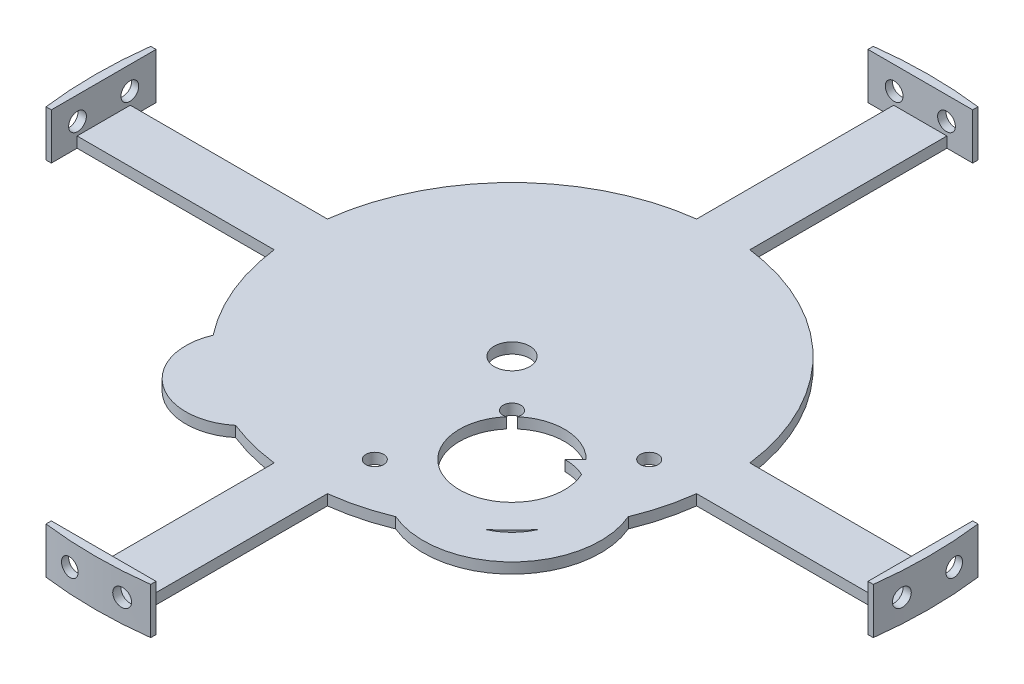
from build123d import *
from build123d.topology import SkipClean

# Parameters (mm, degrees)
SKETCH1_R           = 76.2
BOSS_EXTRUDE1_DEPTH = 3.81
BOSS_EXTRUDE3_DEPTH = 3.81
SKETCH5_R           = 6.35
CUT_EXTRUDE1_DEPTH  = 212.070408513
BOSS_EXTRUDE4_START = -3.81
BOSS_EXTRUDE4_DEPTH = 16.51
SKETCH8_R           = 3.175
CUT_EXTRUDE3_DEPTH  = 332.331209118
CIRPATTERN3_COUNT   = 4
SKETCH9_R           = 3.174999999
CUT_EXTRUDE4_DEPTH  = 3.81
SKETCH11_R          = 31.75
SKETCH11_R_2        = 25.4
BOSS_EXTRUDE5_DEPTH = 3.81
SKETCH12_R          = 25.4
CUT_EXTRUDE5_DEPTH  = 3.81
SKETCH13_R          = 20.52955
SKETCH13_R_2        = 2.3622
BOSS_EXTRUDE7_DEPTH = 3.81
SKETCH14_R          = 2.3622
CUT_EXTRUDE6_DEPTH  = 3.81
SKETCH15_R          = 3.175
CUT_EXTRUDE7_DEPTH  = 3.81
SKETCH16_R          = 25.4
SKETCH16_R_2        = 18.796
BOSS_EXTRUDE8_DEPTH = 3.81
SKETCH17_R          = 3.175
CUT_EXTRUDE8_DEPTH  = 212.417812192
BOSS_EXTRUDE9_START = -3.81
SKETCH19_R          = 3.175
SKETCH19_R_2        = 2.3622
SKETCH19_R_3        = 3.174999999
BOSS_EXTRUDE9_DEPTH = 3.81


with BuildPart() as part:
    # Sketch1 → Boss-Extrude1 (new body)
    with BuildSketch(Plane(origin=(0, 0, 0), x_dir=(1, 0, 0), z_dir=(0, 1, 0))):
        with Locations(Location((0, 0, 0), (0, 0, 90))):
            Circle(SKETCH1_R)
    extrude(amount=BOSS_EXTRUDE1_DEPTH)

    # Sketch3 → Boss-Extrude3 (add)
    with BuildSketch(Plane(origin=(0, 0, 0), x_dir=(-1, 0, 0), z_dir=(0, -1, 0))):
        with BuildLine():
            Line((9.525, -9.525), (148.920700374, -9.525))
            ThreePointArc((148.920700374, -9.525), (149.225, 0), (148.920700374, 9.525))
            Line((148.920700374, 9.525), (9.525, 9.525))
            Line((9.525, 9.525), (9.525, 148.920700374))
            ThreePointArc((9.525, 148.920700374), (0, 149.225), (-9.525, 148.920700374))
            Line((-9.525, 148.920700374), (-9.525, 9.525))
            Line((-9.525, 9.525), (-148.920700374, 9.525))
            ThreePointArc((-148.920700374, 9.525), (-149.225, 0), (-148.920700374, -9.525))
            Line((-148.920700374, -9.525), (-9.525, -9.525))
            Line((-9.525, -9.525), (-9.525, -148.920700374))
            ThreePointArc((-9.525, -148.920700374), (0, -149.225), (9.525, -148.920700374))
            Line((9.525, -148.920700374), (9.525, -9.525))
        make_face()
    extrude(amount=-BOSS_EXTRUDE3_DEPTH)

    # Sketch5 → Cut-Extrude1 (cut, through all)
    with BuildSketch(Plane(origin=(0, 3.81, 0), x_dir=(1, 0, 0), z_dir=(0, 1, 0))):
        with Locations(Location((0, 0, 0), (0, 0, 270))):
            Circle(SKETCH5_R)
    extrude(amount=-CUT_EXTRUDE1_DEPTH, mode=Mode.SUBTRACT)

    # Sketch7 → Boss-Extrude4 (add)
    with BuildSketch(Plane(origin=(0, 3.81, 0), x_dir=(1, 0, 0), z_dir=(0, 1, 0)).offset(BOSS_EXTRUDE4_START)):
        with BuildLine():
            Line((18.739703318, 148.043656212), (18.739703318, 146.138656212))
            Line((18.739703318, 146.138656212), (-18.739703318, 146.138656212))
            Line((-18.739703318, 146.138656212), (-18.739703318, 148.043656212))
            ThreePointArc((-18.739703318, 148.043656212), (0, 149.225), (18.739703318, 148.043656212))
        make_face()
    boss_extrude4 = extrude(amount=BOSS_EXTRUDE4_DEPTH)

    # Sketch8 → Cut-Extrude3 (cut, through all)
    with BuildSketch(Plane.XY.offset(-146.138656212)):
        with Locations((-9.369851659, 8.255)):
            Circle(SKETCH8_R)
        with Locations((9.369851659, 8.255)):
            Circle(SKETCH8_R)
    cut_extrude3 = extrude(amount=-CUT_EXTRUDE3_DEPTH, mode=Mode.SUBTRACT)

    # CirPattern3: Boss-Extrude4, Cut-Extrude3 ×4 about axis
    cirpattern3_axis = Axis((0, 0, 0), (0, 1, 0))
    add([boss_extrude4.rotate(cirpattern3_axis, i * 360 / CIRPATTERN3_COUNT) for i in range(1, CIRPATTERN3_COUNT)])
    add([cut_extrude3.rotate(cirpattern3_axis, i * 360 / CIRPATTERN3_COUNT) for i in range(1, CIRPATTERN3_COUNT)], mode=Mode.SUBTRACT)

    # Sketch9 → Cut-Extrude4 (cut)
    with BuildSketch(Plane.XZ):
        with Locations(Location((-56.514999999, -23.8125, 0), (0, 0, 270))):
            Circle(SKETCH9_R)
        with Locations(Location((-15.874999999, -23.8125, 0), (0, 0, 270))):
            Circle(SKETCH9_R)
    extrude(amount=-CUT_EXTRUDE4_DEPTH, mode=Mode.SUBTRACT)

    # Sketch11 → Boss-Extrude5 (add)
    with BuildSketch(Plane(origin=(0, 3.81, 0), x_dir=(1, 0, 0), z_dir=(0, 1, 0))):
        with Locations((41.275, -41.275)):
            Circle(SKETCH11_R)
        with Locations((41.275, -41.275)):
            Circle(SKETCH11_R_2, mode=Mode.SUBTRACT)
    extrude(amount=-BOSS_EXTRUDE5_DEPTH)

    # Sketch12 → Cut-Extrude5 (cut)
    with BuildSketch(Plane(origin=(0, 3.81, 0), x_dir=(1, 0, 0), z_dir=(0, 1, 0))):
        with Locations(Location((41.275, -41.275, 0), (0, 0, 270))):
            Circle(SKETCH12_R)
    extrude(amount=-CUT_EXTRUDE5_DEPTH, mode=Mode.SUBTRACT)

    # Sketch13 → Boss-Extrude7 (add)
    with BuildSketch(Plane(origin=(0, 3.81, 0), x_dir=(1, 0, 0), z_dir=(0, 1, 0))):
        with Locations((-41.16870274, -55.03340443)):
            Circle(SKETCH13_R)
        with Locations(Location((-41.17109409, -70.730891948, 0), (0, 0, 270))):
            Circle(SKETCH13_R_2, mode=Mode.SUBTRACT)
        with Locations((-41.166311391, -39.335916913)):
            Circle(SKETCH13_R_2, mode=Mode.SUBTRACT)
    extrude(amount=-BOSS_EXTRUDE7_DEPTH)

    # Sketch14 → Cut-Extrude6 (cut)
    with BuildSketch(Plane(origin=(0, 3.81, 0), x_dir=(1, 0, 0), z_dir=(0, 1, 0))):
        with Locations(Location((-41.166311391, -39.335916913, 0), (0, 0, 270))):
            Circle(SKETCH14_R)
    extrude(amount=-CUT_EXTRUDE6_DEPTH, mode=Mode.SUBTRACT)

    # Sketch15 → Cut-Extrude7 (cut)
    with BuildSketch(Plane(origin=(0, 3.81, 0), x_dir=(1, 0, 0), z_dir=(0, 1, 0))):
        with Locations(Location((16.720717023, -16.720717023, 0), (0, 0, 270))):
            Circle(SKETCH15_R)
        with Locations(Location((65.829282977, -16.720717023, 0), (0, 0, 270))):
            Circle(SKETCH15_R)
        with Locations(Location((16.720717023, -65.829282977, 0), (0, 0, 270))):
            Circle(SKETCH15_R)
    extrude(amount=-CUT_EXTRUDE7_DEPTH, mode=Mode.SUBTRACT)

    # Sketch16 → Boss-Extrude8 (add)
    with BuildSketch(Plane(origin=(0, 3.81, 0), x_dir=(1, 0, 0), z_dir=(0, 1, 0))):
        with Locations((41.275, -41.275)):
            Circle(SKETCH16_R)
        with Locations(Location((41.275, -41.275, 0), (0, 0, 270))):
            Circle(SKETCH16_R_2, mode=Mode.SUBTRACT)
    extrude(amount=-BOSS_EXTRUDE8_DEPTH)

    # Sketch17 → Cut-Extrude8 (cut, through all)
    with BuildSketch(Plane(origin=(0, 3.81, 0), x_dir=(1, 0, 0), z_dir=(0, 1, 0))):
        with BuildLine():
            ThreePointArc((24.172548233, -49.072163558), (22.778717915, -37.931773261), (27.984220941, -27.984220941))
            Line((27.984220941, -27.984220941), (18.965781054, -18.965781054))
            ThreePointArc((18.965781054, -18.965781054), (18.376181742, -19.429971822), (17.694108713, -19.742824503))
            ThreePointArc((17.694108713, -19.742824503), (13.616121159, -36.023762469), (24.172548233, -49.072163558))
        make_face()
        with BuildLine():
            Line((18.965781054, -18.965781054), (27.984220941, -27.984220941))
            ThreePointArc((27.984220941, -27.984220941), (34.167406023, -23.874663111), (41.459517866, -22.479905716))
            Line((41.459517866, -22.479905716), (45.26049085, -18.678932732))
            ThreePointArc((45.26049085, -18.678932732), (32.694581443, -13.187694328), (19.742824503, -17.694108713))
            ThreePointArc((19.742824503, -17.694108713), (19.429971822, -18.376181742), (18.965781054, -18.965781054))
        make_face()
        with Locations(Location((56.523994768, -7.415428814, 0), (0, 0, 270))):
            Circle(SKETCH17_R)
        with Locations(Location((7.415428814, -56.523994768, 0), (0, 0, 270))):
            Circle(SKETCH17_R)
    extrude(amount=-CUT_EXTRUDE8_DEPTH, mode=Mode.SUBTRACT)

    # Sketch19 → Boss-Extrude9 (add)
    with SkipClean():  # the faces are left unmerged after this step: merging them gives an invalid solid
        with BuildSketch(Plane(origin=(0, 3.81, 0), x_dir=(1, 0, 0), z_dir=(0, 1, 0)).offset(BOSS_EXTRUDE9_START)):
            with BuildLine():
                ThreePointArc((24.172548233, -49.072163558), (34.587447779, -58.841054232), (48.86207293, -58.471683993))
                ThreePointArc((48.86207293, -58.471683993), (53.881536726, -53.881536726), (58.471683993, -48.86207293))
                ThreePointArc((58.471683993, -48.86207293), (58.841054232, -34.587447779), (49.072163558, -24.172548233))
                ThreePointArc((49.072163558, -24.172548233), (45.26049085, -45.26049085), (24.172548233, -49.072163558))
            make_face()
            with Locations((65.829282977, -16.720717023)):
                Circle(SKETCH19_R)
            with Locations((16.720717023, -65.829282977)):
                Circle(SKETCH19_R)
            with Locations((-41.17109409, -70.730891948)):
                Circle(SKETCH19_R_2)
            with Locations((-41.166311391, -39.335916913)):
                Circle(SKETCH19_R_2)
            with Locations((-15.874999999, 23.8125)):
                Circle(SKETCH19_R_3)
            with Locations((-56.514999999, 23.8125)):
                Circle(SKETCH19_R_3)
        extrude(amount=BOSS_EXTRUDE9_DEPTH)


solid = part.part
